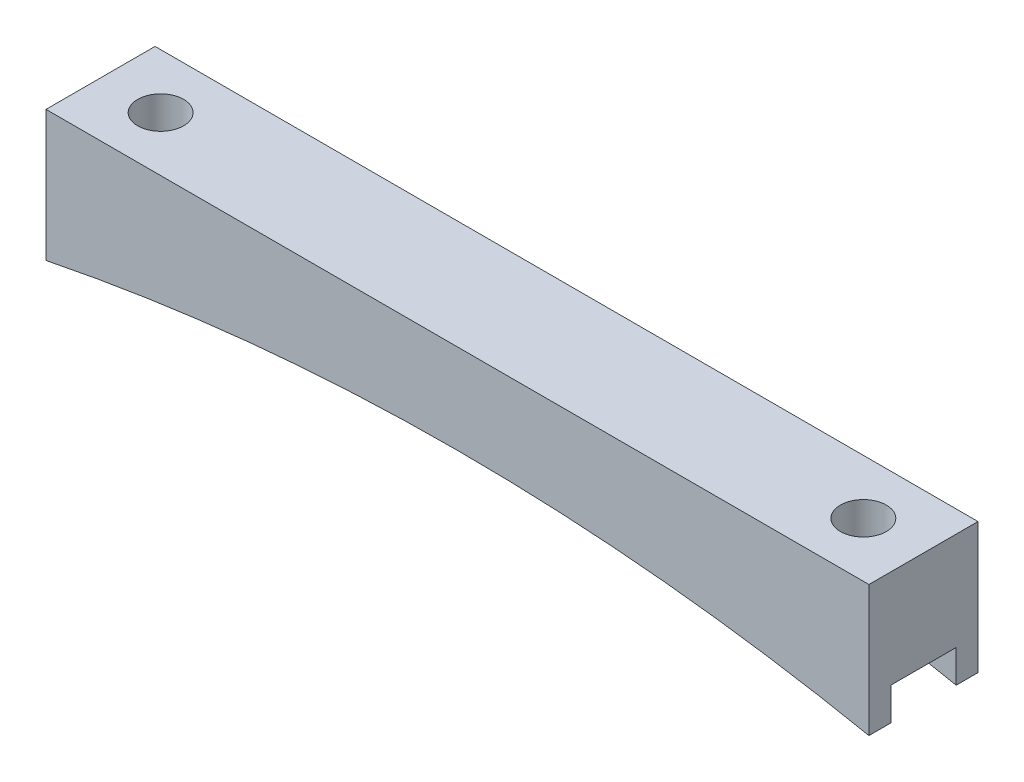
from build123d import *

# Parameters (mm, degrees)
BOSS_EXTRUDE1_DEPTH = 12.7
SKETCH2_R           = 2.675
CUT_EXTRUDE1_DEPTH  = 16.24
SKETCH3_W           = 7.62
SKETCH3_H           = 3.81
CUT_EXTRUDE2_DEPTH  = 96.8300001


with BuildPart() as part:
    # Sketch1 → Boss-Extrude1 (new body)
    with BuildSketch(Plane.XY):
        with BuildLine():
            Line((-47.915, 0), (47.915, 0))
            Line((47.915, 0), (47.915, -15.24))
            ThreePointArc((47.915, -15.24), (0, -10.434910675), (-47.915, -15.24))
            Line((-47.915, -15.24), (-47.915, 0))
        make_face()
    extrude(amount=BOSS_EXTRUDE1_DEPTH)

    # Sketch2 → Cut-Extrude1 (cut, through all)
    with BuildSketch(Plane(origin=(0, 0, 0), x_dir=(1, 0, 0), z_dir=(0, 1, 0))):
        with Locations((-40.915, -6.35)):
            Circle(SKETCH2_R)
        with Locations((40.915, -6.35)):
            Circle(SKETCH2_R)
    extrude(amount=-CUT_EXTRUDE1_DEPTH, mode=Mode.SUBTRACT)

    # Sketch3 → Cut-Extrude2 (cut, through all)
    with BuildSketch(Plane(origin=(47.915, 0, 0), x_dir=(0, 0, -1), z_dir=(1, 0, 0))):
        with Locations((-6.35, -13.335)):
            Rectangle(SKETCH3_W, SKETCH3_H)
    extrude(amount=-CUT_EXTRUDE2_DEPTH, mode=Mode.SUBTRACT)


solid = part.part
